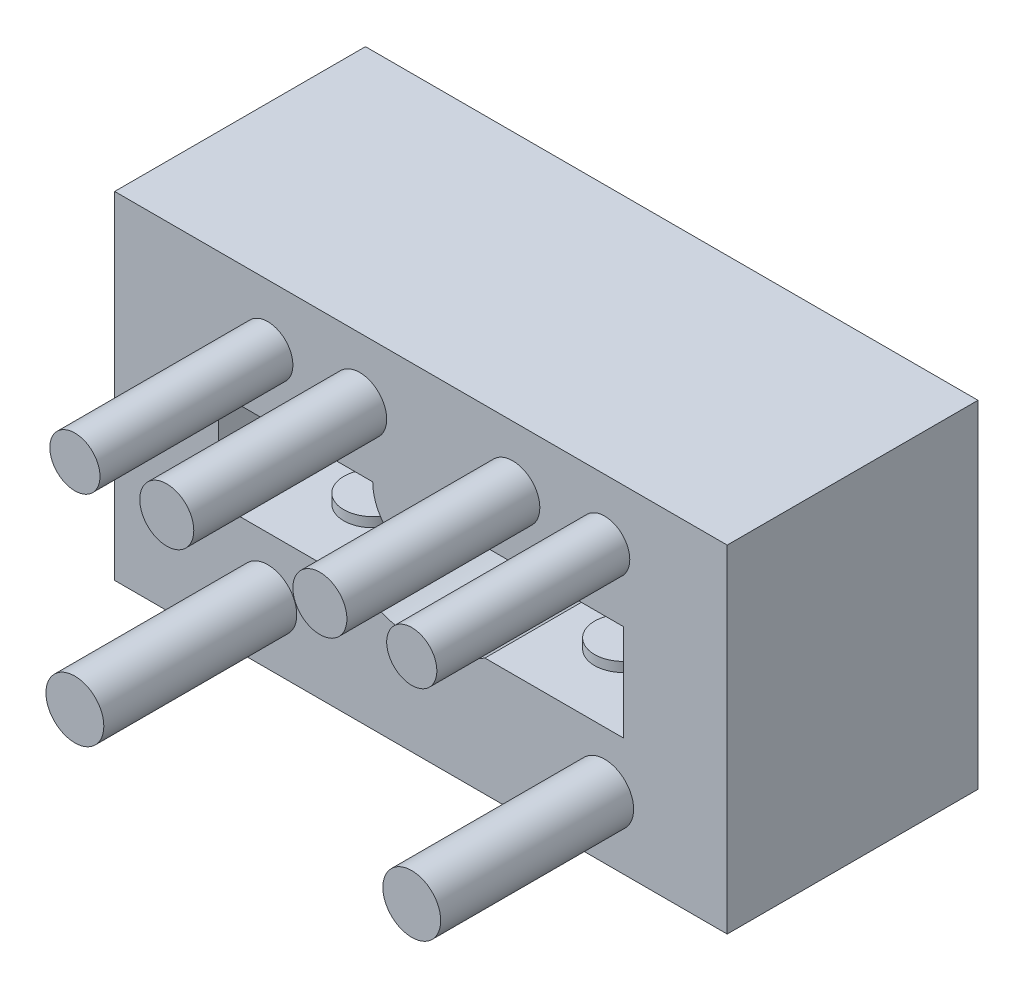
from build123d import *

# Parameters (mm, degrees)
SKETCH1_R      = 24
EXTRUDE1_DEPTH = 5
SKETCH2_R      = 24
EXTRUDE2_DEPTH = 8
SKETCH9_R      = 24
SKETCH9_W      = 31.75
SKETCH9_H      = 17.4625
EXTRUDE4_DEPTH = 13
SKETCH10_R     = 1.3
SKETCH10_R_2   = 1.5
SKETCH10_R_3   = 1.4
EXTRUDE5_DEPTH = 10
SKETCH11_R     = 1.5
EXTRUDE6_DEPTH = 0.5


with BuildPart() as part:
    # Sketch1 → Extrude1 (new body)
    with BuildSketch(Plane.XY):
        Circle(SKETCH1_R)
    extrude(amount=EXTRUDE1_DEPTH)

    # Sketch2 → Extrude2 (add)
    with BuildSketch(Plane.XY.offset(5)):
        Circle(SKETCH2_R)
        with BuildLine():
            Line((-2.5, 0), (-10.5, 0))
            Line((-10.5, 0), (-10.5, -5))
            Line((-10.5, -5), (-3.31662479, -5))
            ThreePointArc((-3.31662479, -5), (0, -6), (3.31662479, -5))
            Line((3.31662479, -5), (10.5, -5))
            Line((10.5, -5), (10.5, 0))
            Line((10.5, 0), (2.5, 0))
            ThreePointArc((2.5, 0), (0, -2.5), (-2.5, 0))
        make_face(mode=Mode.SUBTRACT)
    extrude(amount=EXTRUDE2_DEPTH)

    # Sketch9 → Extrude4 (cut)
    with BuildSketch(Plane.XY.offset(13)):
        Circle(SKETCH9_R)
        with Locations((0, -2.38125)):
            Rectangle(SKETCH9_W, SKETCH9_H, mode=Mode.SUBTRACT)
    extrude(amount=-EXTRUDE4_DEPTH, mode=Mode.SUBTRACT)

    # Sketch10 → Extrude5 (add)
    with BuildSketch(Plane.XY.offset(13)):
        with Locations((9.525, 3.175)):
            Circle(SKETCH10_R)
        with Locations((-7.9375, 3.175)):
            Circle(SKETCH10_R)
        with Locations((-7.9375, -7.9375)):
            Circle(SKETCH10_R_2)
        with Locations((9.525, -7.9375)):
            Circle(SKETCH10_R_2)
        with Locations((-3.175, 3.175)):
            Circle(SKETCH10_R_3)
        with Locations((4.7625, 3.175)):
            Circle(SKETCH10_R_3)
    extrude(amount=EXTRUDE5_DEPTH)

    # Sketch11 → Extrude6 (add)
    with BuildSketch(Plane(origin=(0, -5, 0), x_dir=(1, 0, 0), z_dir=(0, 1, 0))):
        with Locations((-6.5, -9)):
            Circle(SKETCH11_R)
        with Locations((6.5, -9)):
            Circle(SKETCH11_R)
    extrude(amount=EXTRUDE6_DEPTH)


solid = part.part
